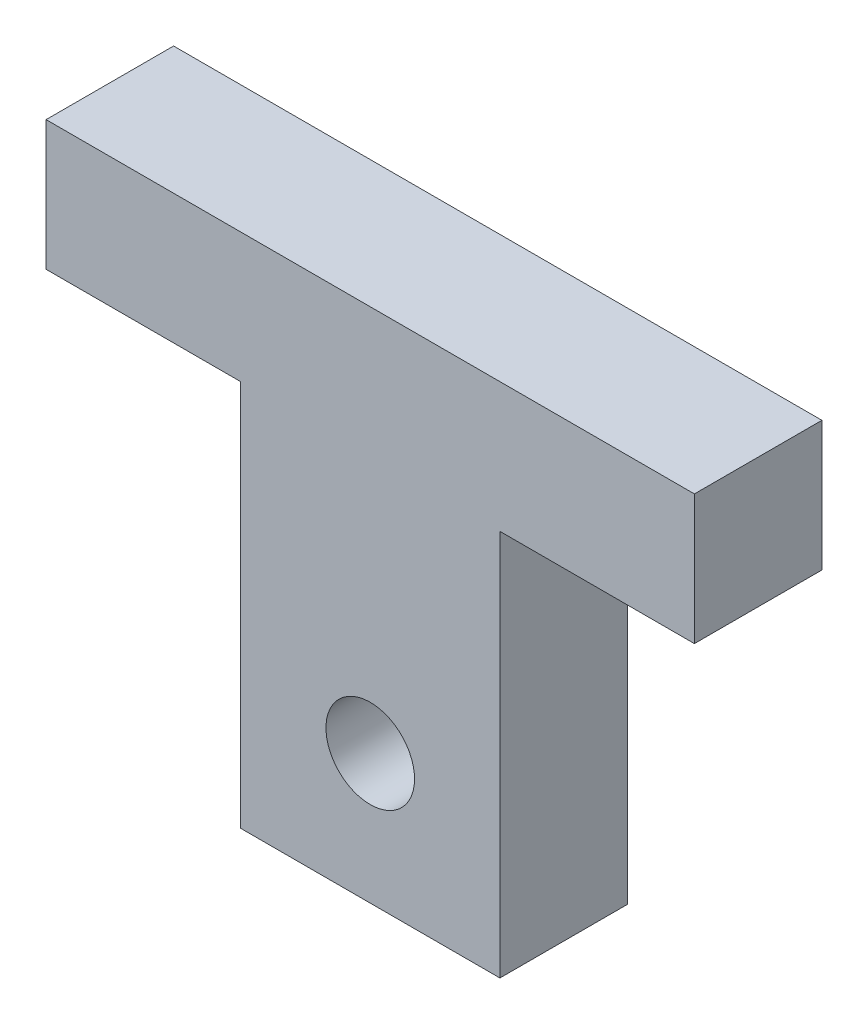
from build123d import *

# Parameters (mm, degrees)
SKETCH1_R           = 2.05
BOSS_EXTRUDE1_DEPTH = 5.9


with BuildPart() as part:
    # Sketch1 → Boss-Extrude1 (new body)
    with BuildSketch(Plane.XY):
        Polygon((-15, -3), (-6, -3), (-6, -20.9), (6, -20.9), (6, -3), (15, -3), (15, 3), (-15, 3), align=None)
        with Locations((0, -14.9)):
            Circle(SKETCH1_R, mode=Mode.SUBTRACT)
    extrude(amount=BOSS_EXTRUDE1_DEPTH)


solid = part.part
